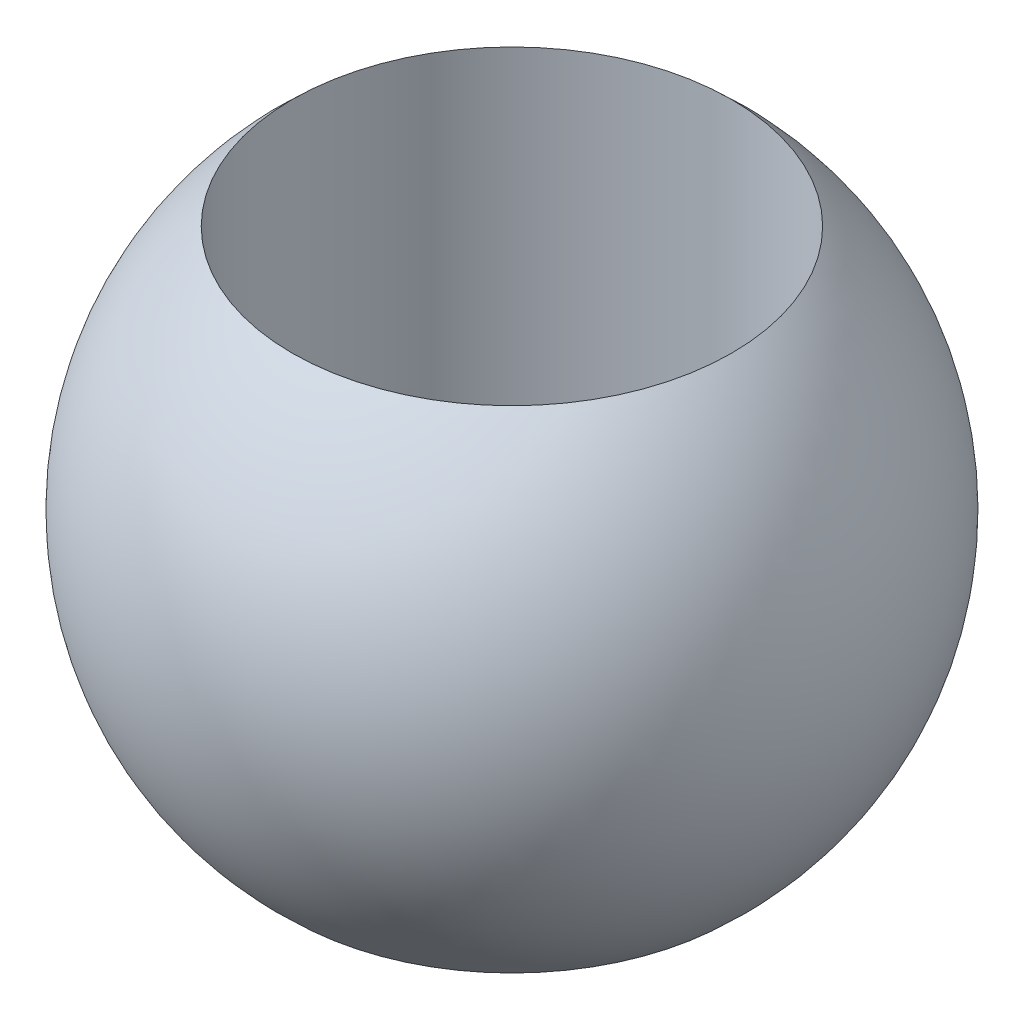
from build123d import *

# Parameters (mm, degrees)
CUT_EXTRUDE1_DEPTH      = 10
CUT_EXTRUDE1_DEPTH_BACK = 10
SKETCH3_R               = 2


with BuildPart() as part:
    # Sketch2 → Revolve2 (revolve)
    with BuildSketch(Plane.XY):
        with BuildLine():
            Line((0, 3), (0, -3))
            ThreePointArc((0, -3), (3, 0), (0, 3))
        make_face()
    revolve(axis=Axis((0, 3, 0), (0, -1, 0)))

    # Sketch3 → Cut-Extrude1 (cut, two sides: drawn at the far end of the back side and taken through both)
    with BuildSketch(Plane(origin=(0, 0, 0), x_dir=(1, 0, 0), z_dir=(0, 1, 0)).offset(-CUT_EXTRUDE1_DEPTH_BACK)):
        Circle(SKETCH3_R)
    extrude(amount=CUT_EXTRUDE1_DEPTH + CUT_EXTRUDE1_DEPTH_BACK, mode=Mode.SUBTRACT)


solid = part.part
